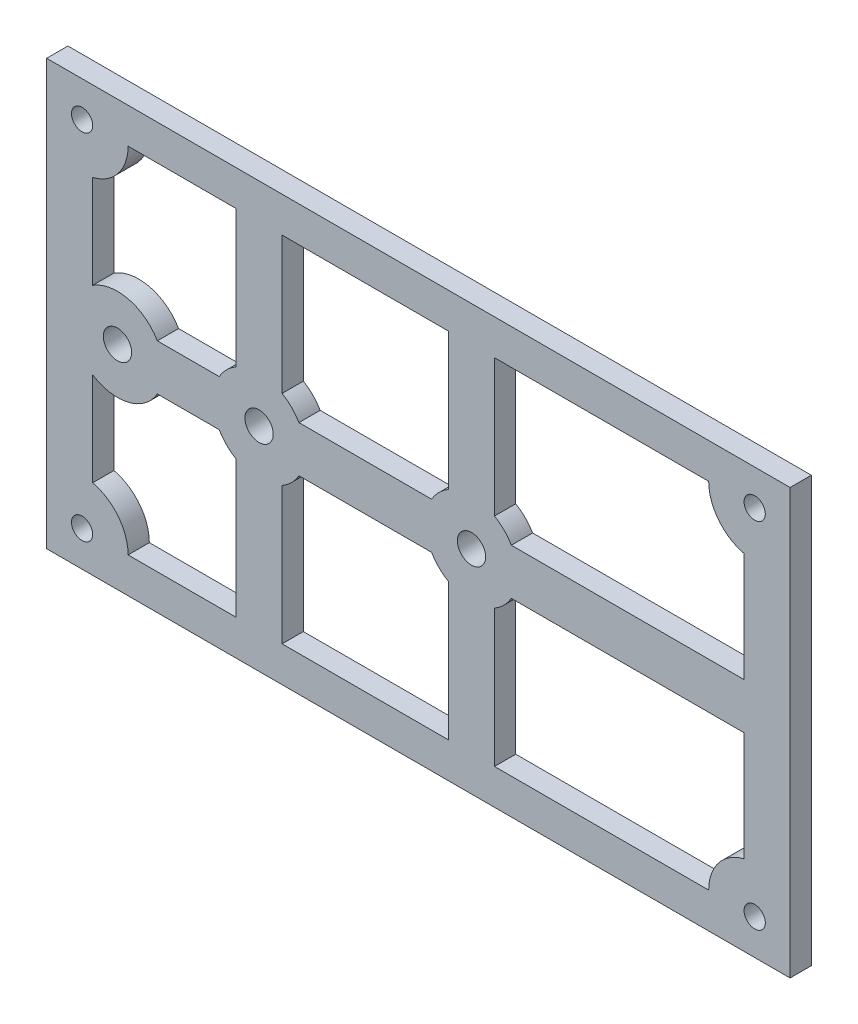
from build123d import *

# Parameters (mm, degrees)
SKETCH2_W           = 105
SKETCH2_H           = 60
BOSS_EXTRUDE1_DEPTH = 3
SKETCH3_R           = 1.5
SKETCH3_R_2         = 2
CUT_EXTRUDE1_DEPTH  = 4
CUT_EXTRUDE2_DEPTH  = 4


with BuildPart() as part:
    # Sketch2 → Boss-Extrude1 (new body)
    with BuildSketch(Plane.XY):
        Rectangle(SKETCH2_W, SKETCH2_H)
    extrude(amount=BOSS_EXTRUDE1_DEPTH)

    # Sketch3 → Cut-Extrude1 (cut, through all)
    with BuildSketch(Plane.XY.offset(3)):
        with Locations((-47.5, 25)):
            Circle(SKETCH3_R)
        with Locations((47.5, 25)):
            Circle(SKETCH3_R)
        with Locations((47.5, -25)):
            Circle(SKETCH3_R)
        with Locations((-47.5, -25)):
            Circle(SKETCH3_R)
        with Locations((-42.5, 0)):
            Circle(SKETCH3_R_2)
        with Locations((-22.5, 0)):
            Circle(SKETCH3_R_2)
        with Locations((7.5, 0)):
            Circle(SKETCH3_R_2)
    extrude(amount=-CUT_EXTRUDE1_DEPTH, mode=Mode.SUBTRACT)

    # Sketch4 → Cut-Extrude2 (cut, through all)
    with BuildSketch(Plane.XY.offset(3)):
        with BuildLine():
            Line((-41, 25), (-25.75, 25))
            Line((-25.75, 25), (-25.75, 5.629165125))
            ThreePointArc((-25.75, 5.629165125), (-27.096194078, 4.596194078), (-28.129165125, 3.25))
            Line((-28.129165125, 3.25), (-36.870834875, 3.25))
            ThreePointArc((-36.870834875, 3.25), (-40.959393148, 6.314786657), (-46, 5.477225575))
            Line((-46, 5.477225575), (-46, 18.67544468))
            ThreePointArc((-46, 18.67544468), (-42.400980486, 20.968871126), (-41, 25))
        make_face()
        with BuildLine():
            Line((-19.25, 25), (4.25, 25))
            Line((4.25, 25), (4.25, 5.629165125))
            ThreePointArc((4.25, 5.629165125), (2.903805922, 4.596194078), (1.870834875, 3.25))
            Line((1.870834875, 3.25), (-16.870834875, 3.25))
            ThreePointArc((-16.870834875, 3.25), (-17.903805922, 4.596194078), (-19.25, 5.629165125))
            Line((-19.25, 5.629165125), (-19.25, 25))
        make_face()
        with BuildLine():
            Line((46, 18.67544468), (46, 3.25))
            Line((46, 3.25), (13.129165125, 3.25))
            ThreePointArc((13.129165125, 3.25), (12.096194078, 4.596194078), (10.75, 5.629165125))
            Line((10.75, 5.629165125), (10.75, 25))
            Line((10.75, 25), (41, 25))
            ThreePointArc((41, 25), (42.400980486, 20.968871126), (46, 18.67544468))
        make_face()
        with BuildLine():
            Line((46, -3.25), (13.129165125, -3.25))
            ThreePointArc((13.129165125, -3.25), (12.096194078, -4.596194078), (10.75, -5.629165125))
            Line((10.75, -5.629165125), (10.75, -25))
            Line((10.75, -25), (41, -25))
            ThreePointArc((41, -25), (42.400980486, -20.968871126), (46, -18.67544468))
            Line((46, -18.67544468), (46, -3.25))
        make_face()
        with BuildLine():
            Line((-16.870834875, -3.25), (1.870834875, -3.25))
            ThreePointArc((1.870834875, -3.25), (2.903805922, -4.596194078), (4.25, -5.629165125))
            Line((4.25, -5.629165125), (4.25, -25))
            Line((4.25, -25), (-19.25, -25))
            Line((-19.25, -25), (-19.25, -5.629165125))
            ThreePointArc((-19.25, -5.629165125), (-17.903805922, -4.596194078), (-16.870834875, -3.25))
        make_face()
        with BuildLine():
            Line((-46, -18.67544468), (-46, -5.477225575))
            ThreePointArc((-46, -5.477225575), (-40.959393148, -6.314786657), (-36.870834875, -3.25))
            Line((-36.870834875, -3.25), (-28.129165125, -3.25))
            ThreePointArc((-28.129165125, -3.25), (-27.096194078, -4.596194078), (-25.75, -5.629165125))
            Line((-25.75, -5.629165125), (-25.75, -25))
            Line((-25.75, -25), (-41, -25))
            ThreePointArc((-41, -25), (-42.400980486, -20.968871126), (-46, -18.67544468))
        make_face()
    extrude(amount=-CUT_EXTRUDE2_DEPTH, mode=Mode.SUBTRACT)


solid = part.part
